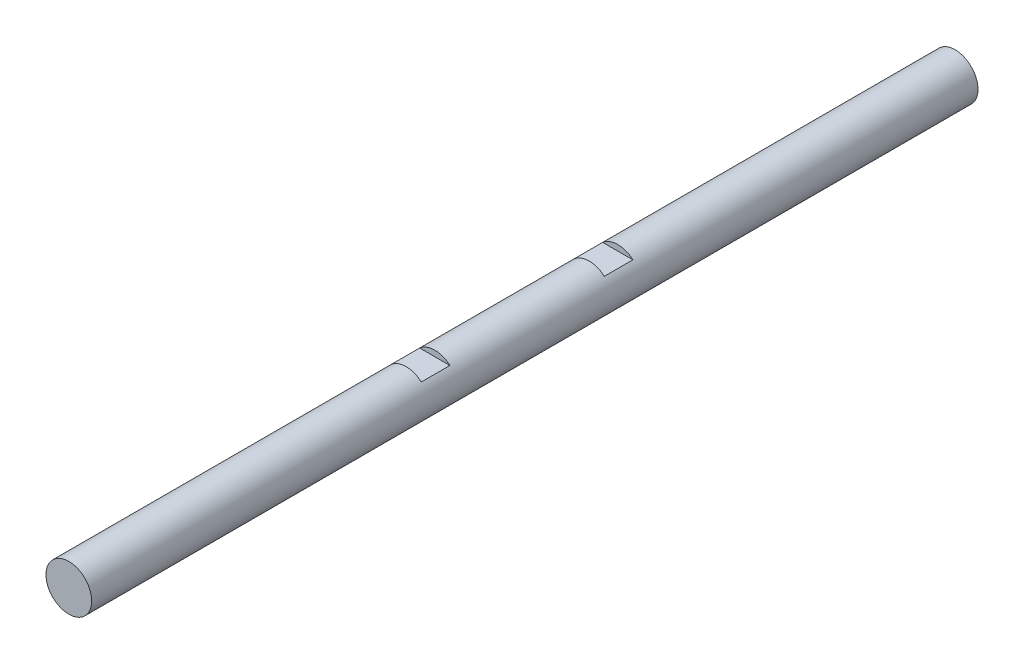
from build123d import *

# Parameters (mm, degrees)
BOSS_EXTRUDE1_DEPTH      = 77.5
BOSS_EXTRUDE1_DEPTH_BACK = 77.5
SKETCH1_R                = 4
CUT_EXTRUDE1_DEPTH       = 78.706177361
CUT_EXTRUDE1_DEPTH_BACK  = 78.706177361
SKETCH3_W                = 5
SKETCH3_H                = 1


with BuildPart() as part:
    # Sketch1 → Boss-Extrude1 (new, two sides: drawn at the far end of the back side and taken through both)
    with BuildSketch(Plane.XY.offset(-BOSS_EXTRUDE1_DEPTH_BACK)):
        Circle(SKETCH1_R)
    extrude(amount=BOSS_EXTRUDE1_DEPTH + BOSS_EXTRUDE1_DEPTH_BACK)

    # Sketch3 → Cut-Extrude1 (cut, two sides: drawn at the far end of the back side and taken through both)
    with BuildSketch(Plane(origin=(0, 0, 0), x_dir=(0, 0, -1), z_dir=(1, 0, 0)).offset(-CUT_EXTRUDE1_DEPTH_BACK)):
        with Locations((16, 3.5)):
            Rectangle(SKETCH3_W, SKETCH3_H)
        with Locations((-16, 3.5)):
            Rectangle(SKETCH3_W, SKETCH3_H)
    extrude(amount=CUT_EXTRUDE1_DEPTH + CUT_EXTRUDE1_DEPTH_BACK, mode=Mode.SUBTRACT)


solid = part.part
